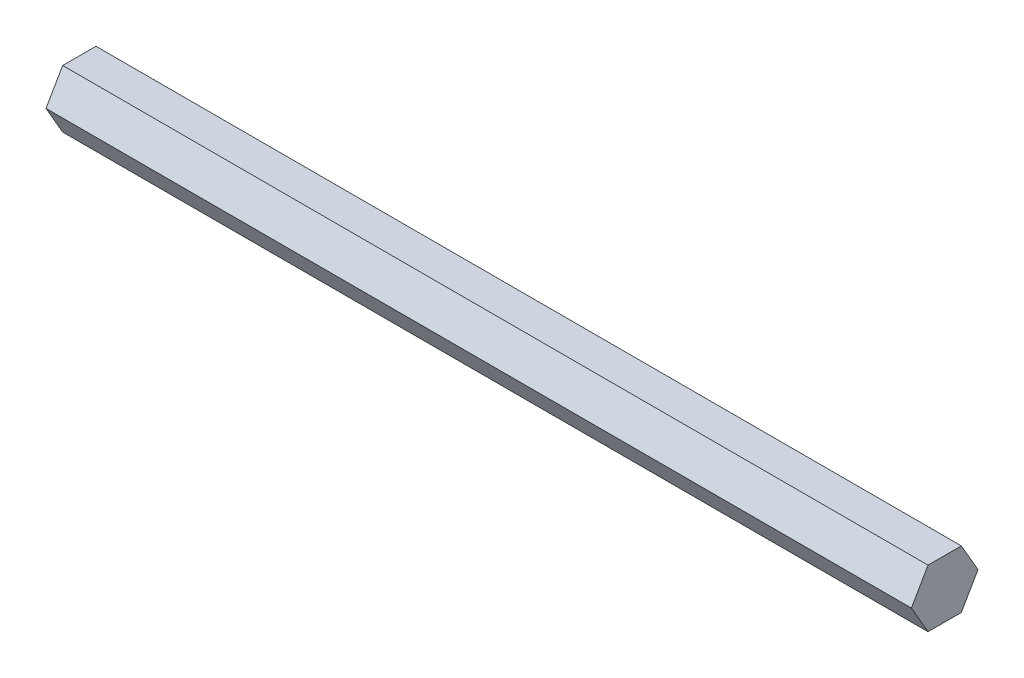
from build123d import *

# Parameters (mm, degrees)
BOSS_EXTRUDE1_DEPTH = 190.5


with BuildPart() as part:
    # Sketch1 → Boss-Extrude1 (new body)
    with BuildSketch(Plane(origin=(0, 0, 0), x_dir=(0, 0, -1), z_dir=(1, 0, 0))):
        Polygon((7.332348419, 0), (3.666174209, 6.35), (-3.666174209, 6.35), (-7.332348419, 0), (-3.666174209, -6.35), (3.666174209, -6.35), align=None)
    extrude(amount=BOSS_EXTRUDE1_DEPTH)


solid = part.part
